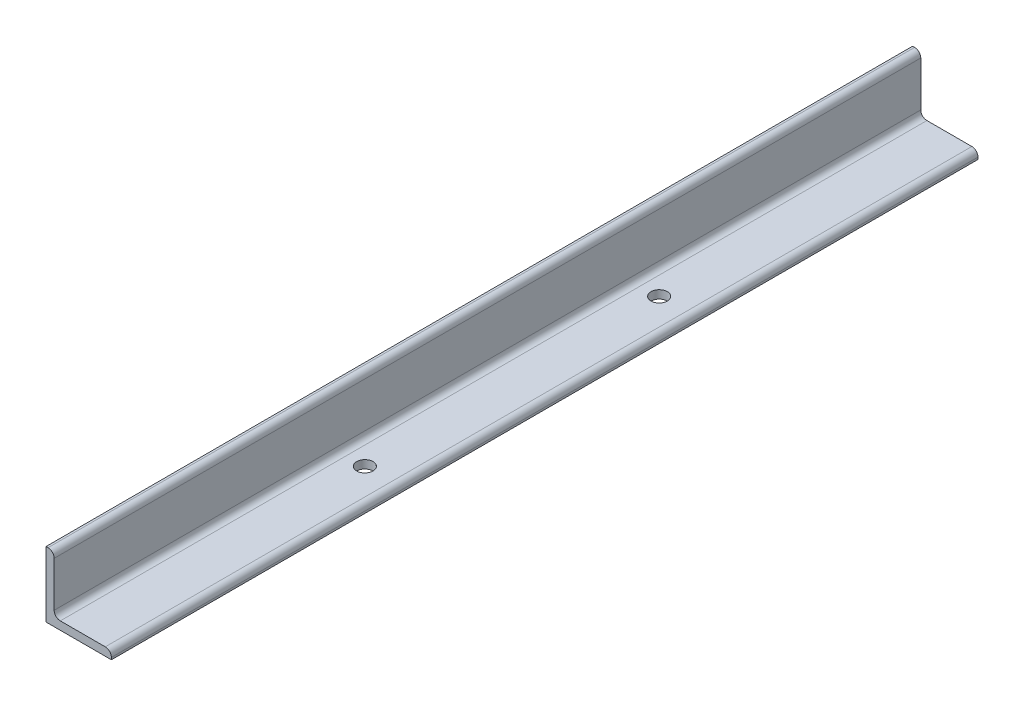
from build123d import *

# Parameters (mm, degrees)
BOSS_EXTRUDE1_DEPTH = 336.55
SKETCH2_R           = 6.35
CUT_EXTRUDE1_DEPTH  = 51.8


with BuildPart() as part:
    # Sketch1 → Boss-Extrude1 (new body, symmetric)
    with BuildSketch(Plane.XY):
        with BuildLine():
            Line((0, 0), (0, 50.8))
            Line((0, 50.8), (1.59258, 50.8))
            ThreePointArc((1.59258, 50.8), (4.956583943, 49.406583943), (6.35, 46.04258))
            Line((6.35, 46.04258), (6.35, 11.1125))
            ThreePointArc((6.35, 11.1125), (7.744903955, 7.744903955), (11.1125, 6.35))
            Line((11.1125, 6.35), (46.04258, 6.35))
            ThreePointArc((46.04258, 6.35), (49.406583943, 4.956583943), (50.8, 1.59258))
            Line((50.8, 1.59258), (50.8, 0))
            Line((50.8, 0), (0, 0))
        make_face()
    extrude(amount=BOSS_EXTRUDE1_DEPTH, both=True)

    # Sketch2 → Cut-Extrude1 (cut, through all)
    with BuildSketch(Plane.XZ):
        with Locations((25.4, -114.3)):
            Circle(SKETCH2_R)
        with Locations((25.4, 114.3)):
            Circle(SKETCH2_R)
    extrude(amount=-CUT_EXTRUDE1_DEPTH, mode=Mode.SUBTRACT)


solid = part.part
